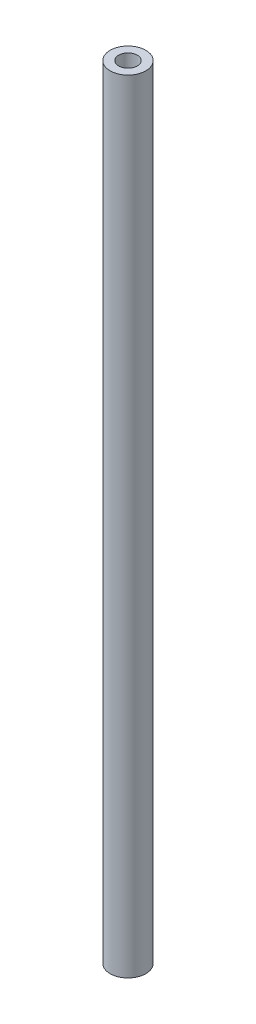
from build123d import *

# Parameters (mm, degrees)
SKETCH_1_R          = 4
EXTRUDE_1_DEPTH     = 175.5
SKETCH_2_R          = 2.1
CUT_EXTRUDE_1_DEPTH = 6
SKETCH_3_R          = 2.1
CUT_EXTRUDE_2_DEPTH = 6


with BuildPart() as part:
    # ｽｹｯﾁ1 → ﾎﾞｽ - 押し出し1 (new body)
    with BuildSketch(Plane(origin=(0, 0, 0), x_dir=(1, 0, 0), z_dir=(0, 1, 0))):
        Circle(SKETCH_1_R)
    extrude(amount=EXTRUDE_1_DEPTH)

    # ｽｹｯﾁ2 → ｶｯﾄ - 押し出し1 (cut)
    with BuildSketch(Plane(origin=(0, 175.5, 0), x_dir=(1, 0, 0), z_dir=(0, 1, 0))):
        Circle(SKETCH_2_R)
    extrude(amount=-CUT_EXTRUDE_1_DEPTH, mode=Mode.SUBTRACT)

    # ｽｹｯﾁ3 → ｶｯﾄ - 押し出し2 (cut)
    with BuildSketch(Plane.XZ):
        Circle(SKETCH_3_R)
    extrude(amount=-CUT_EXTRUDE_2_DEPTH, mode=Mode.SUBTRACT)


solid = part.part
